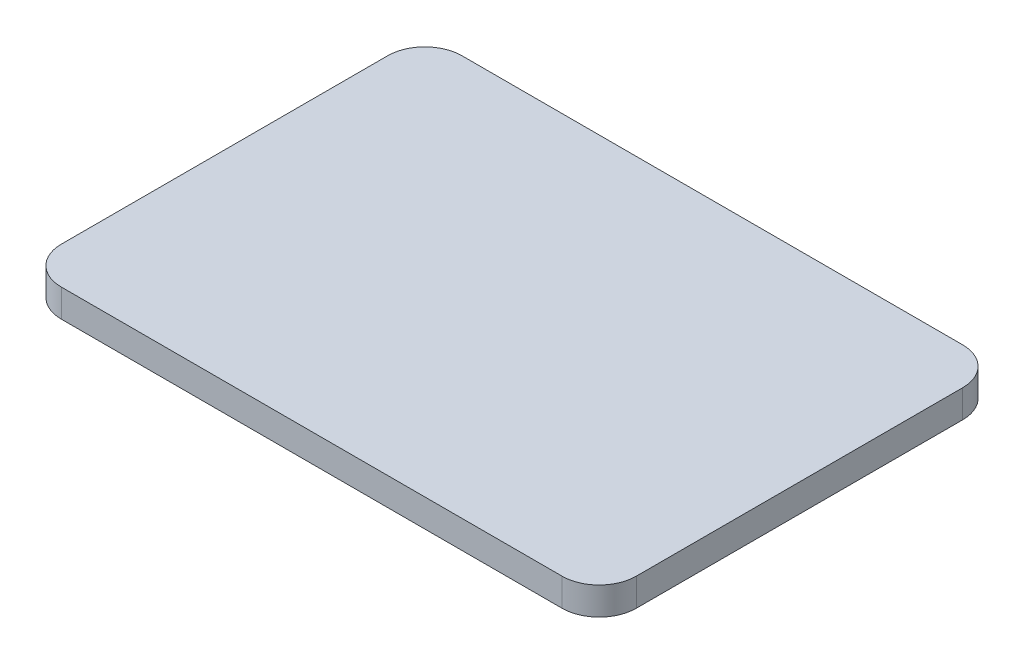
from build123d import *

# Parameters (mm, degrees)
EXTRUDE_1_DEPTH = 15


with BuildPart() as part:
    # Эскиз1 → Бобышка-Вытянуть1 (new body)
    with BuildSketch(Plane(origin=(0, 0, 0), x_dir=(1, 0, 0), z_dir=(0, 1, 0))):
        with BuildLine():
            Line((-135, 108), (135, 108))
            ThreePointArc((135, 108), (149.142135624, 102.142135624), (155, 88))
            Line((155, 88), (155, -88))
            ThreePointArc((155, -88), (149.142135624, -102.142135624), (135, -108))
            Line((135, -108), (-135, -108))
            ThreePointArc((-135, -108), (-149.142135624, -102.142135624), (-155, -88))
            Line((-155, -88), (-155, 88))
            ThreePointArc((-155, 88), (-149.142135624, 102.142135624), (-135, 108))
        make_face()
    extrude(amount=EXTRUDE_1_DEPTH)


solid = part.part
